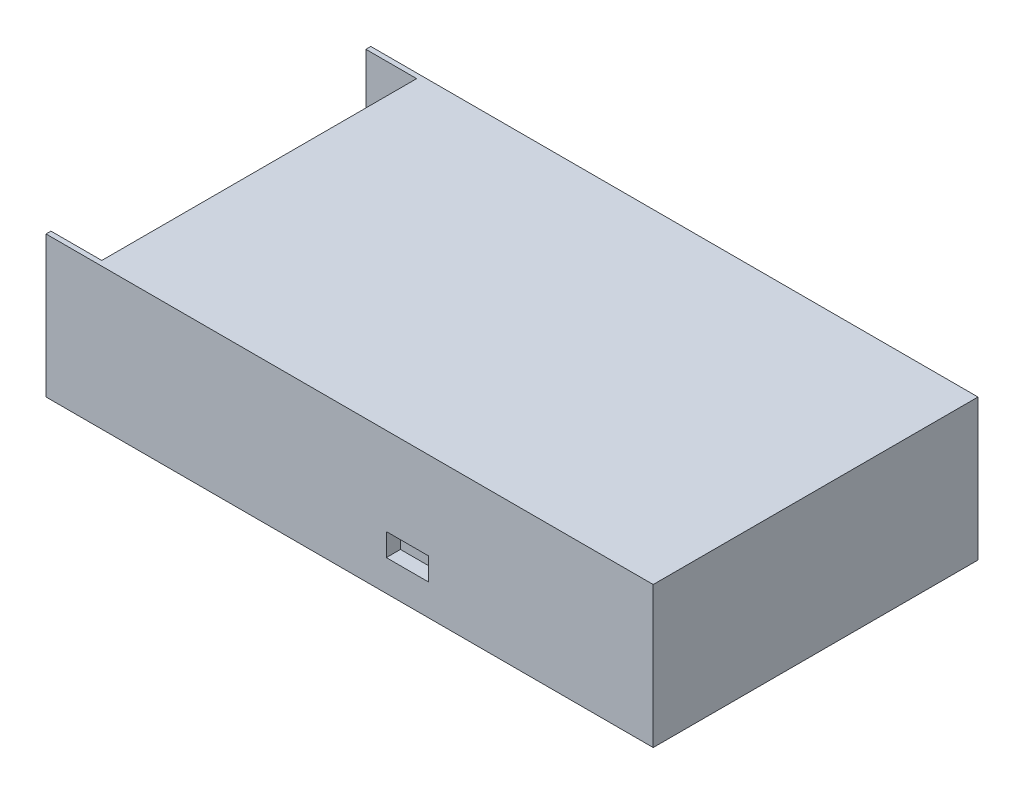
from build123d import *

# Parameters (mm, degrees)
SKETCH1_W           = 215
SKETCH1_H           = 115
BOSS_EXTRUDE1_DEPTH = 50
SKETCH2_W           = 18
SKETCH2_H           = 111.5
CUT_EXTRUDE1_DEPTH  = 41.25
SKETCH3_R           = 2
CUT_EXTRUDE2_DEPTH  = 5
SKETCH4_W           = 15
SKETCH4_H           = 8
CUT_EXTRUDE3_DEPTH  = 5


with BuildPart() as part:
    # Sketch1 → Boss-Extrude1 (new body)
    with BuildSketch(Plane(origin=(0, 0, 0), x_dir=(1, 0, 0), z_dir=(0, 1, 0))):
        Rectangle(SKETCH1_W, SKETCH1_H)
    extrude(amount=BOSS_EXTRUDE1_DEPTH)

    # Sketch2 → Cut-Extrude1 (cut)
    with BuildSketch(Plane(origin=(0, 50, 0), x_dir=(1, 0, 0), z_dir=(0, 1, 0))):
        with Locations((-98.5, 0)):
            Rectangle(SKETCH2_W, SKETCH2_H)
    extrude(amount=-CUT_EXTRUDE1_DEPTH, mode=Mode.SUBTRACT)

    # Sketch3 → Cut-Extrude2 (cut)
    with BuildSketch(Plane.XZ):
        with Locations(Location((-75, -25, 0), (0, 0, 270))):  # turned: the seam where the file's is
            Circle(SKETCH3_R)
        with Locations(Location((-75, 25, 0), (0, 0, 270))):  # turned: the seam where the file's is
            Circle(SKETCH3_R)
        with Locations(Location((75, -25, 0), (0, 0, 270))):  # turned: the seam where the file's is
            Circle(SKETCH3_R)
        with Locations(Location((75, 25, 0), (0, 0, 270))):  # turned: the seam where the file's is
            Circle(SKETCH3_R)
    extrude(amount=-CUT_EXTRUDE2_DEPTH, mode=Mode.SUBTRACT)

    # Sketch4 → Cut-Extrude3 (cut)
    with BuildSketch(Plane.XY.offset(57.5)):
        with Locations((20.5, 15)):
            Rectangle(SKETCH4_W, SKETCH4_H)
    extrude(amount=-CUT_EXTRUDE3_DEPTH, mode=Mode.SUBTRACT)


solid = part.part
